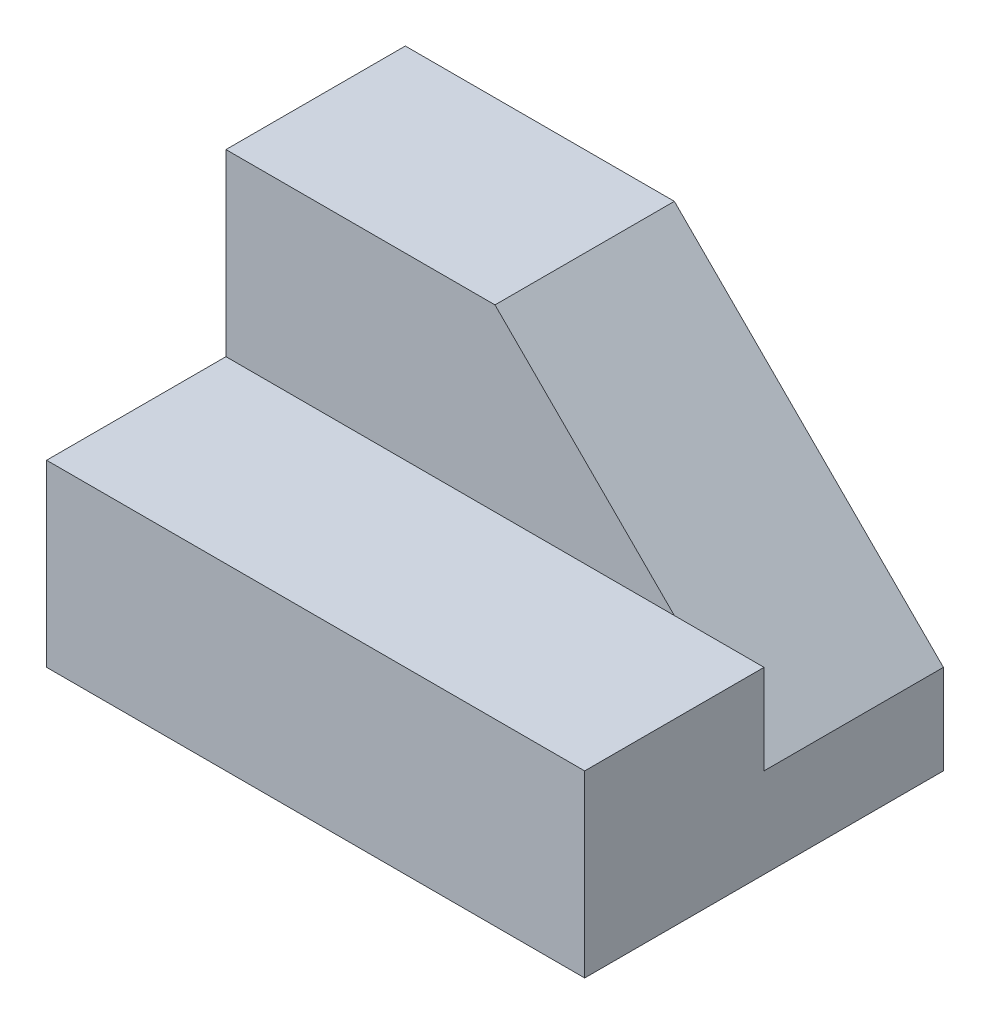
from build123d import *

# Parameters (mm, degrees)
SKETCH_1_W          = 30
SKETCH_1_H          = 20
EXTRUDE_1_DEPTH     = 10
SKETCH_1_3_W        = 30
SKETCH_1_3_H        = 10
EXTRUDE_2_DEPTH     = 20
CUT_EXTRUDE_1_DEPTH = 10


with BuildPart() as part:
    # 草圖1 → 填料-伸長1 (new body)
    with BuildSketch(Plane(origin=(0, 0, 0), x_dir=(1, 0, 0), z_dir=(0, 1, 0))):
        Rectangle(SKETCH_1_W, SKETCH_1_H)
    extrude(amount=EXTRUDE_1_DEPTH)

    # 草圖1<3> → 填料-伸長2 (add)
    with BuildSketch(Plane(origin=(0, 0, 0), x_dir=(1, 0, 0), z_dir=(0, 1, 0))):
        with Locations((0, 5)):
            Rectangle(SKETCH_1_3_W, SKETCH_1_3_H)
    extrude(amount=EXTRUDE_2_DEPTH)

    # 草圖2 → 除料-伸長1 (cut)
    with BuildSketch(Plane(origin=(0, 0, -10), x_dir=(-1, 0, 0), z_dir=(0, 0, -1))):
        Polygon((-15, 5), (0, 20), (-15, 20), align=None)
    extrude(amount=-CUT_EXTRUDE_1_DEPTH, mode=Mode.SUBTRACT)


solid = part.part
